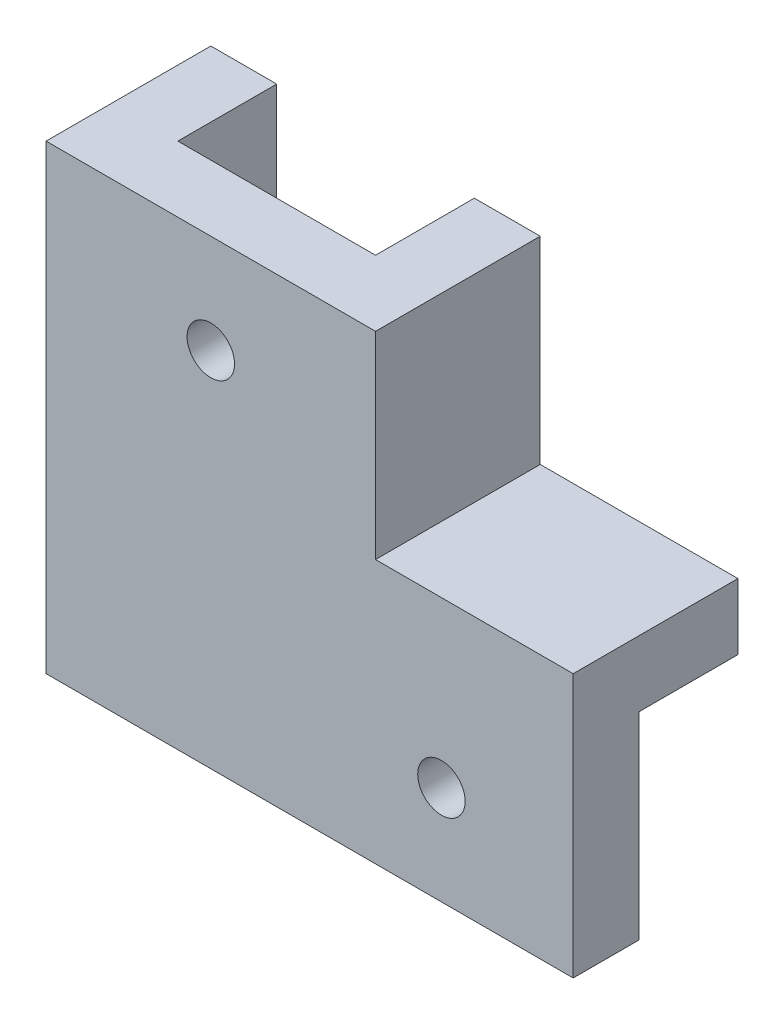
from build123d import *

# Parameters (mm, degrees)
BOSS_EXTRUDE1_DEPTH = 5
BOSS_EXTRUDE2_DEPTH = 7.5
SKETCH3_W           = 5
SKETCH3_H           = 35
BOSS_EXTRUDE3_DEPTH = 7.5
SKETCH4_W           = 5
SKETCH4_H           = 35
BOSS_EXTRUDE4_DEPTH = 5
BOSS_EXTRUDE5_DEPTH = 5
SKETCH7_R           = 1.8
CUT_EXTRUDE1_DEPTH  = 6


with BuildPart() as part:
    # Sketch1 → Boss-Extrude1 (new body)
    with BuildSketch(Plane.XY):
        Polygon((-7.529880478, -25.806772908), (27.470119522, -25.806772908), (27.470119522, -10.806772908), (7.470119522, -10.806772908), (7.470119522, 9.193227092), (-7.529880478, 9.193227092), align=None)
    extrude(amount=BOSS_EXTRUDE1_DEPTH)



with BuildPart() as body_2:
    # Sketch2 → Boss-Extrude2 (new body)
    with BuildSketch(Plane(origin=(0, 0, 0), x_dir=(-1, 0, 0), z_dir=(0, 0, -1))):
        Polygon((-7.470119522, 9.193227092), (-12.470119522, 9.193227092), (-12.470119522, -5.806772908), (-27.470119522, -5.806772908), (-27.470119522, -10.806772908), (-7.470119522, -10.806772908), align=None)
    extrude(amount=BOSS_EXTRUDE2_DEPTH)


with BuildPart() as body_3:
    # Sketch3 → Boss-Extrude3 (new body)
    with BuildSketch(Plane(origin=(0, 0, 0), x_dir=(-1, 0, 0), z_dir=(0, 0, -1))):
        with Locations((10.029880478, -8.306772908)):
            Rectangle(SKETCH3_W, SKETCH3_H)
    extrude(amount=BOSS_EXTRUDE3_DEPTH)


with BuildPart() as part_1:
    add(part.part)

    add(body_3.part)  # Boss-Extrude4 merges body 3
    # Sketch4 → Boss-Extrude4 (add)
    with BuildSketch(Plane.XY):
        with Locations((-10.029880478, -8.306772908)):
            Rectangle(SKETCH4_W, SKETCH4_H)
    extrude(amount=BOSS_EXTRUDE4_DEPTH)


    add(body_2.part)  # Boss-Extrude5 merges body 2
    # Sketch5 → Boss-Extrude5 (add)
    with BuildSketch(Plane.XY):
        Polygon((7.470119522, 9.193227092), (7.470119522, -10.806772908), (27.470119522, -10.806772908), (27.470119522, -5.806772908), (12.470119522, -5.806772908), (12.470119522, 9.193227092), align=None)
    extrude(amount=BOSS_EXTRUDE5_DEPTH)

    # Sketch7 → Cut-Extrude1 (cut, through all)
    with BuildSketch(Plane(origin=(0, 0, 0), x_dir=(-1, 0, 0), z_dir=(0, 0, -1))):
        with Locations((0.029880478, 1.693227092)):
            Circle(SKETCH7_R)
        with Locations((-17.470119522, -18.306772908)):
            Circle(SKETCH7_R)
    extrude(amount=-CUT_EXTRUDE1_DEPTH, mode=Mode.SUBTRACT)


solid = part_1.part
